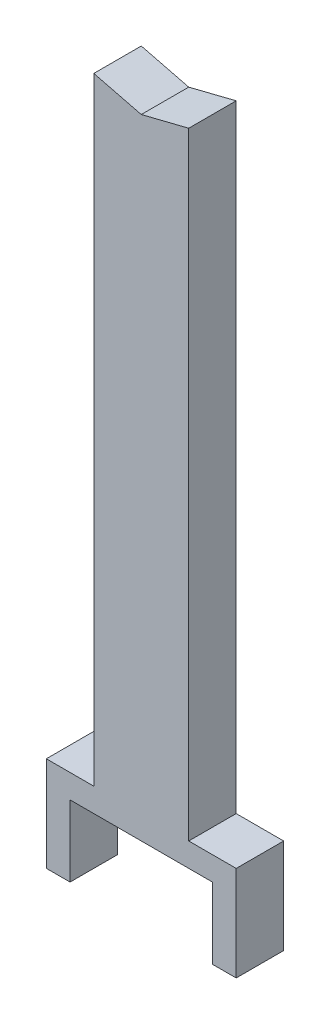
from build123d import *

# Parameters (mm, degrees)
BOSS_EXTRUDE1_DEPTH = 25.4


with BuildPart() as part:
    # Sketch1 → Boss-Extrude1 (new body, symmetric)
    with BuildSketch(Plane.XY):
        Polygon((0, 749.554), (-50.8, 762.254), (-50.8, 101.6), (-101.6, 101.6), (-101.6, 0), (-76.2, 0), (-76.2, 76.2), (0, 76.2), (76.2, 76.2), (76.2, 0), (101.6, 0), (101.6, 101.6), (50.8, 101.6), (50.8, 762.254), align=None)
    extrude(amount=BOSS_EXTRUDE1_DEPTH, both=True)


solid = part.part
